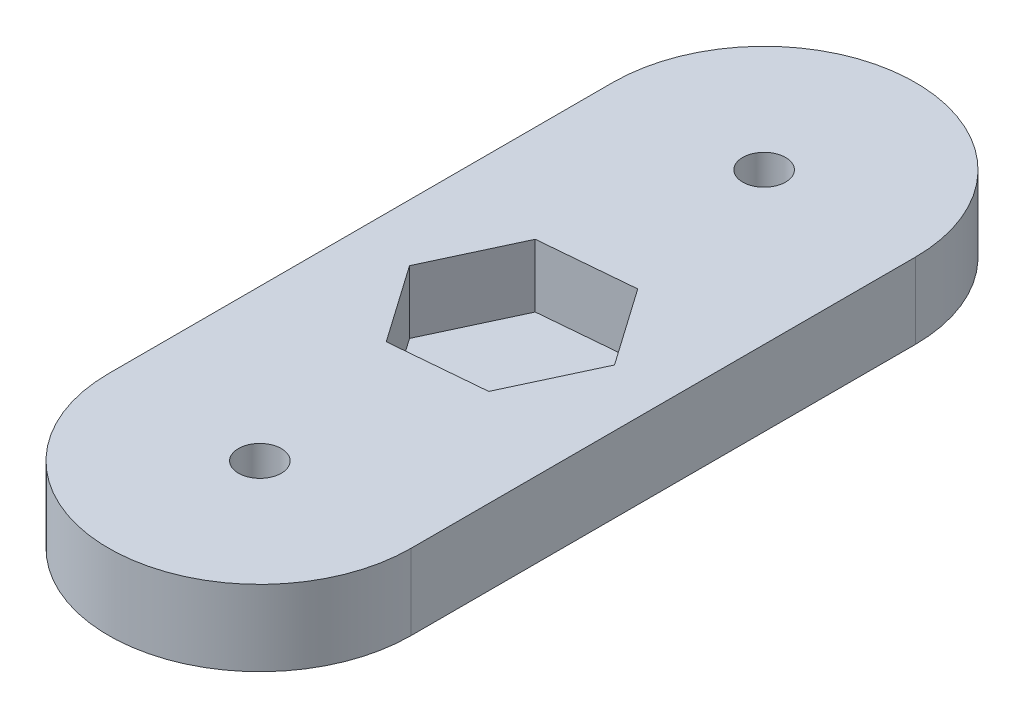
from build123d import *

# Parameters (mm, degrees)
SKETCH1_R           = 1.7
BOSS_EXTRUDE1_DEPTH = 6
CUT_EXTRUDE1_DEPTH  = 5


with BuildPart() as part:
    # Sketch1 → Boss-Extrude1 (new body)
    with BuildSketch(Plane(origin=(0, 0, 0), x_dir=(1, 0, 0), z_dir=(0, 1, 0))):
        with BuildLine():
            Line((-12, 0), (-12, 40))
            ThreePointArc((-12, 40), (0, 52), (12, 40))
            Line((12, 40), (12, 0))
            ThreePointArc((12, 0), (0, -12), (-12, 0))
        make_face()
        with Locations((0, 40)):
            Circle(SKETCH1_R, mode=Mode.SUBTRACT)
        Circle(SKETCH1_R, mode=Mode.SUBTRACT)
    extrude(amount=BOSS_EXTRUDE1_DEPTH)

    # Sketch2 → Cut-Extrude1 (cut)
    with BuildSketch(Plane(origin=(0, 6, 0), x_dir=(1, 0, 0), z_dir=(0, 1, 0))):
        Polygon((4.305008629, 13.851810507), (7.476992602, 20.65415209), (3.171983973, 26.802341583), (-4.305008629, 26.148189493), (-7.476992602, 19.34584791), (-3.171983973, 13.197658417), align=None)
    extrude(amount=-CUT_EXTRUDE1_DEPTH, mode=Mode.SUBTRACT)


solid = part.part
